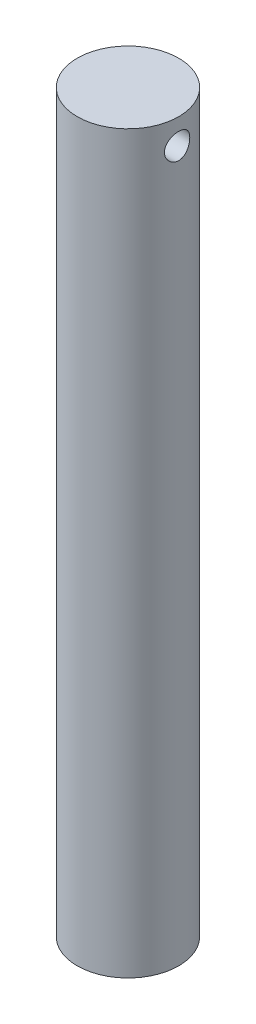
from build123d import *

# Parameters (mm, degrees)
SKETCH2_R               = 12.7
BOSS_EXTRUDE3_DEPTH     = 184.15
SKETCH3_R               = 3.175
CUT_EXTRUDE1_DEPTH      = 13.7
CUT_EXTRUDE1_DEPTH_BACK = 13.7


with BuildPart() as part:
    # Sketch2 → Boss-Extrude3 (new body)
    with BuildSketch(Plane(origin=(0, 0, 0), x_dir=(1, 0, 0), z_dir=(0, 1, 0))):
        Circle(SKETCH2_R)
    extrude(amount=BOSS_EXTRUDE3_DEPTH)

    # Sketch3 → Cut-Extrude1 (cut, two sides)
    with BuildSketch(Plane(origin=(0, 0, 0), x_dir=(0, 0, -1), z_dir=(1, 0, 0))) as cut_extrude1_sk:
        with Locations((0, 177.8)):
            Circle(SKETCH3_R)
    extrude(amount=CUT_EXTRUDE1_DEPTH, mode=Mode.SUBTRACT)
    extrude(cut_extrude1_sk.sketch, amount=-CUT_EXTRUDE1_DEPTH_BACK, mode=Mode.SUBTRACT)


solid = part.part
